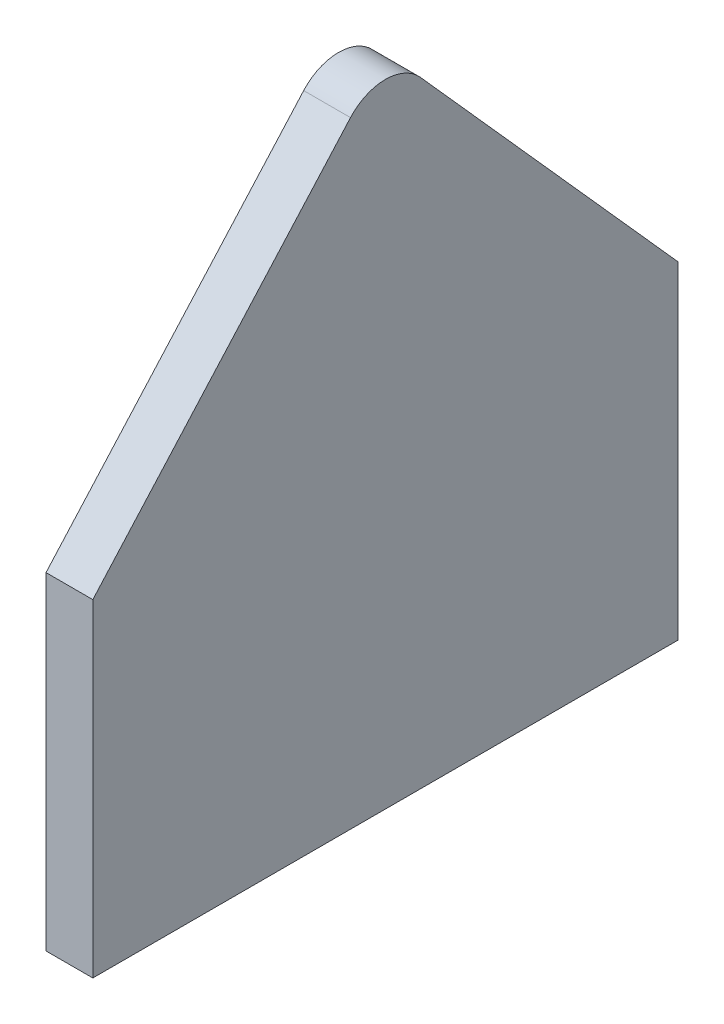
from build123d import *

# Parameters (mm, degrees)
BOSS_EXTRUDE1_DEPTH = 2
FILLET1_R           = 2


with BuildPart() as part:
    # Sketch1 → Boss-Extrude1 (new body)
    with BuildSketch(Plane(origin=(0, 0, 0), x_dir=(0, 0, -1), z_dir=(1, 0, 0))):
        Polygon((12.5, 0), (-12.5, 0), (-12.5, 14), (0, 28), (12.5, 14), align=None)
    extrude(amount=BOSS_EXTRUDE1_DEPTH)

    # Fillet1
    fillet1_edges = [part.edges().sort_by_distance(p)[0] for p in [
        (1, 28, 0),
    ]]
    fillet(fillet1_edges, radius=FILLET1_R)


solid = part.part
